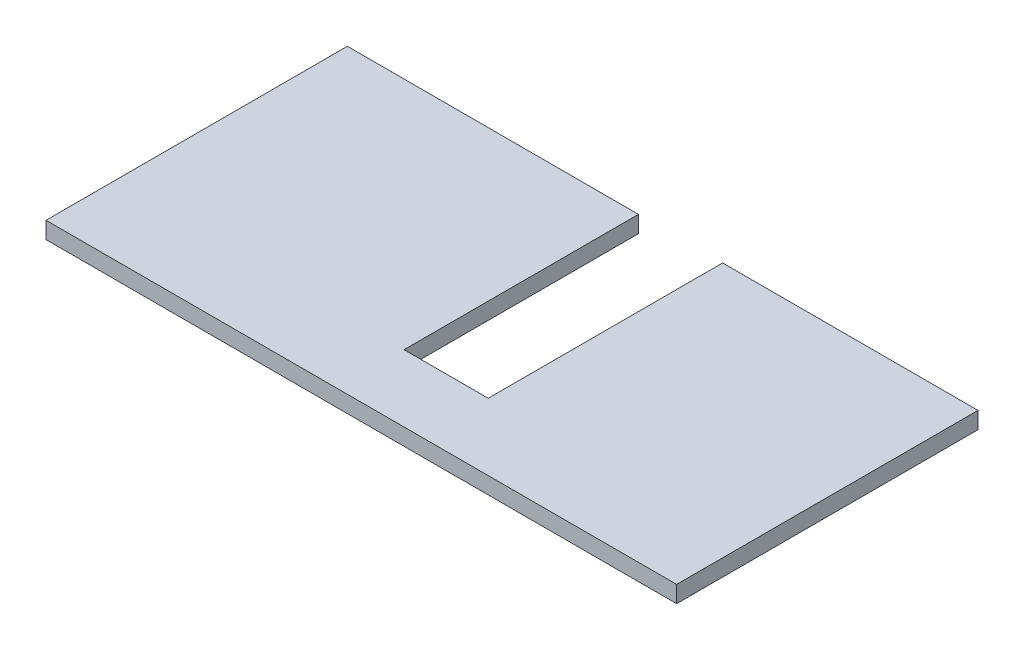
from build123d import *

# Parameters (mm, degrees)
ESBO_O1_W                = 5650
ESBO_O1_H                = 150
RESSALTO_EXTRUS_O1_DEPTH = 2700
ESBO_O2_W                = 754
ESBO_O2_H                = 2100
CORTE_EXTRUS_O1_DEPTH    = 151


with BuildPart() as part:
    # Esboço1 → Ressalto-extrusão1 (new body)
    with BuildSketch(Plane.XY):
        with Locations((2825, 75)):
            Rectangle(ESBO_O1_W, ESBO_O1_H)
    extrude(amount=RESSALTO_EXTRUS_O1_DEPTH)

    # Esboço2 → Corte-extrusão1 (cut, through all)
    with BuildSketch(Plane(origin=(0, 150, 0), x_dir=(1, 0, 0), z_dir=(0, 1, 0))):
        with Locations((2985, -1050)):
            Rectangle(ESBO_O2_W, ESBO_O2_H)
    extrude(amount=-CORTE_EXTRUS_O1_DEPTH, mode=Mode.SUBTRACT)


solid = part.part
